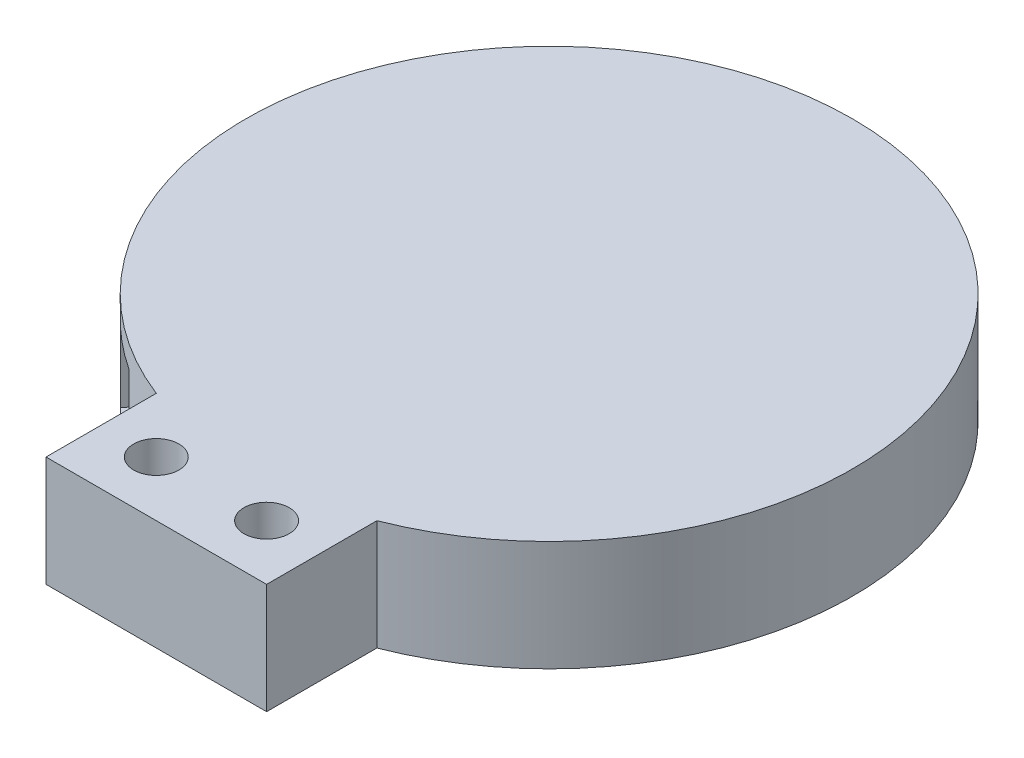
from build123d import *

# Parameters (mm, degrees)
SKETCH1_R           = 55
BOSS_EXTRUDE1_DEPTH = 20
SKETCH9_W           = 40
SKETCH9_H           = 20
BOSS_EXTRUDE4_DEPTH = 20
SKETCH11_R          = 4.1
CUT_EXTRUDE6_DEPTH  = 21
SKETCH12_R          = 52
CUT_EXTRUDE7_DEPTH  = 17
BOSS_EXTRUDE5_DEPTH = 17
SKETCH14_W          = 12.8
SKETCH14_H          = 15
CUT_EXTRUDE8_DEPTH  = 39.466128658
SKETCH16_W          = 35
SKETCH16_H          = 15
CUT_EXTRUDE9_DEPTH  = 10
CHAMFER1_SIZE       = 1
CHAMFER1_SIZE2      = 2.747477419


with BuildPart() as part:
    # Sketch1 → Boss-Extrude1 (new body)
    with BuildSketch(Plane(origin=(0, 0, 0), x_dir=(1, 0, 0), z_dir=(0, 1, 0))):
        with Locations(Location((0, 0, 0), (0, 0, 270))):  # turned: the seam where the file's is
            Circle(SKETCH1_R)
    extrude(amount=BOSS_EXTRUDE1_DEPTH)

    # Sketch9 → Boss-Extrude4 (add)
    with BuildSketch(Plane.XZ):
        with Locations((0, 61.23475383)):
            Rectangle(SKETCH9_W, SKETCH9_H)
    extrude(amount=-BOSS_EXTRUDE4_DEPTH)

    # Sketch11 → Cut-Extrude6 (cut, through all)
    with BuildSketch(Plane(origin=(0, 20, 0), x_dir=(1, 0, 0), z_dir=(0, 1, 0))):
        with Locations(Location((-10, -61.23475383, 0), (0, 0, 270))):  # turned: the seam where the file's is
            Circle(SKETCH11_R)
        with Locations(Location((10, -61.23475383, 0), (0, 0, 270))):  # turned: the seam where the file's is
            Circle(SKETCH11_R)
    extrude(amount=-CUT_EXTRUDE6_DEPTH, mode=Mode.SUBTRACT)

    # Sketch12 → Cut-Extrude7 (cut)
    with BuildSketch(Plane.XZ):
        with Locations(Location((0, 0, 0), (0, 0, 270))):  # turned: the seam where the file's is
            Circle(SKETCH12_R)
    extrude(amount=-CUT_EXTRUDE7_DEPTH, mode=Mode.SUBTRACT)

    # Sketch13 → Boss-Extrude5 (add)
    with BuildSketch(Plane.XZ):
        Polygon((-27.329455823, 44.239132501), (-38.821330473, 34.596304721), (-36.242802171, 41.369787173), align=None)
    extrude(amount=-BOSS_EXTRUDE5_DEPTH)

    # Sketch14 → Cut-Extrude8 (cut, through all)
    with BuildSketch(Plane(origin=(-33.075393148, 0, 39.417718611), x_dir=(-0.766044443, 0, -0.64278761), z_dir=(0.64278761, 0, -0.766044443))):
        with Locations((0, 8.5)):
            Rectangle(SKETCH14_W, SKETCH14_H)
    extrude(amount=-CUT_EXTRUDE8_DEPTH, mode=Mode.SUBTRACT)

    # Sketch16 → Cut-Extrude9 (cut)
    with BuildSketch(Plane.XZ):
        with Locations((0, 61.23475383)):
            Rectangle(SKETCH16_W, SKETCH16_H)
    extrude(amount=-CUT_EXTRUDE9_DEPTH, mode=Mode.SUBTRACT)

    # Chamfer1
    chamfer1_edges = [part.edges().sort_by_distance(p)[0] for p in [
        (17.5, 0, 61.23475383),
        (0, 0, 68.73475383),
        (-17.5, 0, 61.23475383),
        (0, 0, 53.73475383),
    ]]
    chamfer1_side = [part.faces().sort_by_distance(p)[0] for p in [
        (-18.325628086, 0, 61.23475383),
    ]]
    chamfer(chamfer1_edges, length=CHAMFER1_SIZE, length2=CHAMFER1_SIZE2, reference=chamfer1_side[0])


solid = part.part
